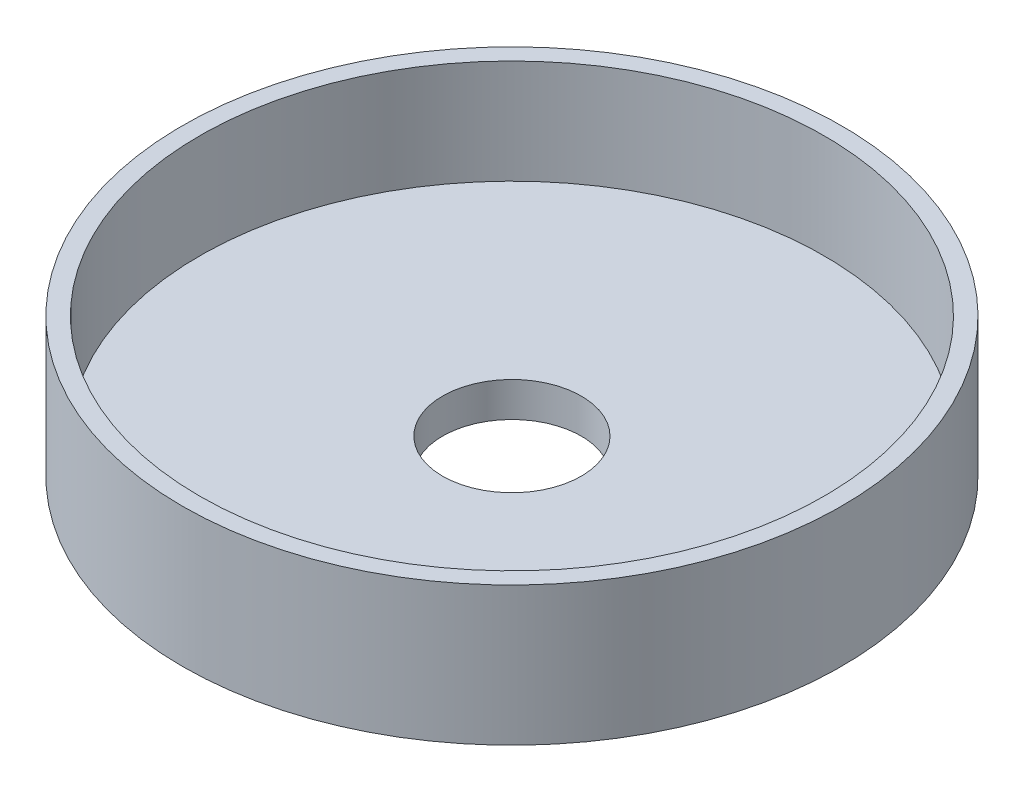
from build123d import *

# Parameters (mm, degrees)
SKETCH1_R           = 23.75
BOSS_EXTRUDE1_DEPTH = 10
SKETCH2_R           = 22.5
CUT_EXTRUDE1_DEPTH  = 7.5
SKETCH3_R           = 5
CUT_EXTRUDE2_DEPTH  = 7.5


with BuildPart() as part:
    # Sketch1 → Boss-Extrude1 (new body)
    with BuildSketch(Plane(origin=(0, 0, 0), x_dir=(1, 0, 0), z_dir=(0, 1, 0))):
        Circle(SKETCH1_R)
    extrude(amount=BOSS_EXTRUDE1_DEPTH)

    # Sketch2 → Cut-Extrude1 (cut)
    with BuildSketch(Plane(origin=(0, 10, 0), x_dir=(1, 0, 0), z_dir=(0, 1, 0))):
        Circle(SKETCH2_R)
    extrude(amount=-CUT_EXTRUDE1_DEPTH, mode=Mode.SUBTRACT)

    # Sketch3 → Cut-Extrude2 (cut)
    with BuildSketch(Plane(origin=(0, 2.5, 0), x_dir=(1, 0, 0), z_dir=(0, 1, 0))):
        Circle(SKETCH3_R)
    extrude(amount=-CUT_EXTRUDE2_DEPTH, mode=Mode.SUBTRACT)


solid = part.part
